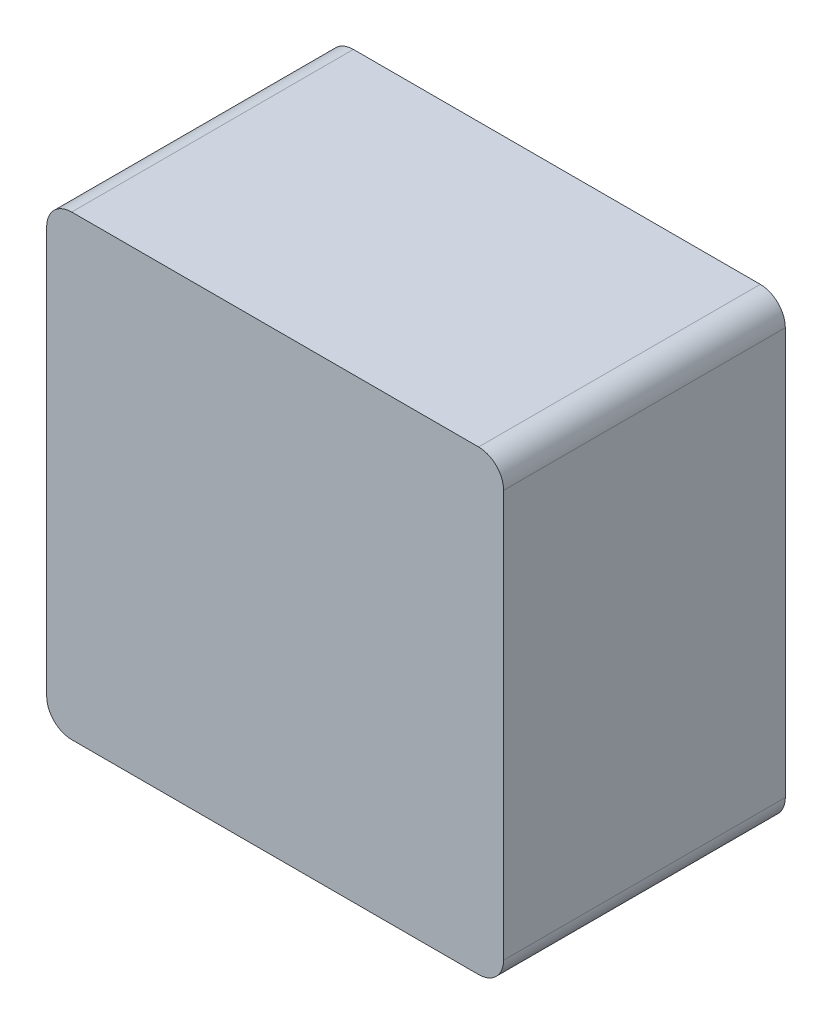
from build123d import *

# Parameters (mm, degrees)
ESQUISSE1_W             = 7.3
ESQUISSE1_H             = 7.3
BOSS_EXTRU_1_DEPTH      = 4.5
CONG_1_R                = 0.4
ESQUISSE2_R             = 3.194001284
ENL_V_MAT_EXTRU_1_DEPTH = 0.5
ESQUISSE4_R             = 2.722665782
BOSS_EXTRU_2_DEPTH      = 0.5
CONG_2_R                = 0.1
CONG_3_R                = 0.1
ESQUISSE5_W             = 0.110070801
ESQUISSE5_H             = 0.110070801
ENL_V_MAT_EXTRU_2_DEPTH = 0.15


with BuildPart() as part:
    # Esquisse1 → Boss.-Extru.1 (new body)
    with BuildSketch(Plane.XY):
        Rectangle(ESQUISSE1_W, ESQUISSE1_H)
    extrude(amount=BOSS_EXTRU_1_DEPTH)

    # Congé1
    cong_1_edges = [part.edges().sort_by_distance(p)[0] for p in [
        (3.65, -3.65, 2.25),
        (-3.65, -3.65, 2.25),
        (-3.65, 3.65, 2.25),
        (3.65, 3.65, 2.25),
    ]]
    fillet(cong_1_edges, radius=CONG_1_R)

    # Esquisse2 → Enlèv. mat.-Extru.1 (cut)
    with BuildSketch(Plane(origin=(0, 0, 0), x_dir=(-1, 0, 0), z_dir=(0, 0, -1))):
        Circle(ESQUISSE2_R)
    extrude(amount=-ENL_V_MAT_EXTRU_1_DEPTH, mode=Mode.SUBTRACT)

    # Esquisse4 → Boss.-Extru.2 (add)
    with BuildSketch(Plane(origin=(0, 0, 0.5), x_dir=(-1, 0, 0), z_dir=(0, 0, -1))):
        Circle(ESQUISSE4_R)
    extrude(amount=BOSS_EXTRU_2_DEPTH)

    # Congé2
    cong_2_edges = [part.edges().sort_by_distance(p)[0] for p in [
        (2.722665782, 0, 0),
    ]]
    fillet(cong_2_edges, radius=CONG_2_R)

    # Congé3
    cong_3_edges = [part.edges().sort_by_distance(p)[0] for p in [
        (3.194001284, 0, 0),
    ]]
    fillet(cong_3_edges, radius=CONG_3_R)

    # Esquisse5 → Enlèv. mat.-Extru.2 (cut)
    with BuildSketch(Plane(origin=(0, 0, 0), x_dir=(-1, 0, 0), z_dir=(0, 0, -1))):
        with BuildLine():
            add(Edge.make_bspline(
                [(-0.934817078, 0.083251061), (-0.928955448, 0.081995484), (-0.917467244, 0.07953468), (-0.900940309, 0.074214743), (-0.88562815, 0.0674044), (-0.871243346, 0.059681976), (-0.858158053, 0.050281794), (-0.846155594, 0.039704894), (-0.83522412, 0.027794835), (-0.825475205, 0.014775308), (-0.817032773, 0.000884688), (-0.809399465, -0.013262172), (-0.803016569, -0.027741979), (-0.797817027, -0.042594032), (-0.793736289, -0.057688985), (-0.790942899, -0.073174388), (-0.789178597, -0.088902263), (-0.788916836, -0.099518177), (-0.788785646, -0.104838674)],
                knots=[0, 0, 0, 0, 1.7977e-05, 3.5233e-05, 5.1965e-05, 6.82e-05, 8.4121e-05, 0.000100183, 0.000116117, 0.000132534, 0.000148891, 0.000164839, 0.00018073, 0.000196306, 0.000212008, 0.000227586, 0.000243471, 0.000259431, 0.000259431, 0.000259431, 0.000259431], degree=3))
            add(Edge.make_bspline(
                [(-0.788785646, -0.104838674), (-0.789046711, -0.113344299), (-0.789559799, -0.130060944), (-0.792984015, -0.154560432), (-0.798944283, -0.17783618), (-0.807350159, -0.199929267), (-0.817933009, -0.221001066), (-0.831218583, -0.240711955), (-0.846660871, -0.259371296), (-0.864378941, -0.276485435), (-0.883666398, -0.29203868), (-0.904068164, -0.305702124), (-0.925379623, -0.317368932), (-0.947727579, -0.326736661), (-0.970938921, -0.334173202), (-0.995149022, -0.339250482), (-1.020253593, -0.342482377), (-1.037320898, -0.342903319), (-1.045982333, -0.343116941)],
                knots=[0, 0, 0, 0, 2.5516e-05, 5.0148e-05, 7.4038e-05, 9.7443e-05, 0.000120938, 0.000144614, 0.000168597, 0.000193474, 0.000218381, 0.000242838, 0.000267045, 0.000291148, 0.000315426, 0.000340051, 0.000365262, 0.000391239, 0.000391239, 0.000391239, 0.000391239], degree=3))
            add(Edge.make_bspline(
                [(-1.045982333, -0.343116941), (-1.05422647, -0.342950254), (-1.070399565, -0.342623251), (-1.09406705, -0.339657235), (-1.116686533, -0.335315361), (-1.138069305, -0.328553388), (-1.158537675, -0.32037952), (-1.177756847, -0.309981996), (-1.19590383, -0.297817127), (-1.212887842, -0.284017603), (-1.22832784, -0.268463629), (-1.242300717, -0.251792798), (-1.254437288, -0.233732346), (-1.264890302, -0.214590233), (-1.273553823, -0.194142376), (-1.280544902, -0.17259103), (-1.285961492, -0.149795802), (-1.288045572, -0.134099866), (-1.289107468, -0.126102351)],
                knots=[0, 0, 0, 0, 2.4721e-05, 4.8497e-05, 7.1464e-05, 9.3718e-05, 0.000115668, 0.000137493, 0.000159132, 0.000181133, 0.000203023, 0.000224784, 0.000246293, 0.000268192, 0.000290118, 0.000312812, 0.000336098, 0.000360288, 0.000360288, 0.000360288, 0.000360288], degree=3))
            Line((-1.289107468, -0.126102351), (-1.189043104, -0.112968903))
            add(Edge.make_bspline(
                [(-1.189043104, -0.112968903), (-1.187869842, -0.119084022), (-1.185588589, -0.13097407), (-1.180981695, -0.148015924), (-1.175868995, -0.163923344), (-1.169917951, -0.178660921), (-1.163271775, -0.192224935), (-1.155835105, -0.204528163), (-1.147857078, -0.215724232), (-1.139121523, -0.225797432), (-1.129489933, -0.234545988), (-1.119314216, -0.242322367), (-1.108285068, -0.248772031), (-1.096492784, -0.253891553), (-1.084040381, -0.25799322), (-1.070856449, -0.260982315), (-1.056918951, -0.262676847), (-1.047393948, -0.262934315), (-1.04254262, -0.26306545)],
                knots=[0, 0, 0, 0, 1.8674e-05, 3.6309e-05, 5.2922e-05, 6.8774e-05, 8.3948e-05, 9.8186e-05, 0.000111854, 0.00012515, 0.000138097, 0.000150824, 0.000163508, 0.000176319, 0.000189322, 0.000202787, 0.000216809, 0.000231363, 0.000231363, 0.000231363, 0.000231363], degree=3))
            add(Edge.make_bspline(
                [(-1.04254262, -0.26306545), (-1.037274024, -0.262889623), (-1.026906493, -0.262543632), (-1.011630134, -0.26057244), (-0.997071807, -0.256857145), (-0.982993851, -0.252115273), (-0.969709522, -0.245512409), (-0.956762053, -0.237980552), (-0.944770896, -0.228585182), (-0.933363946, -0.218186466), (-0.922992346, -0.206725321), (-0.913846492, -0.194492646), (-0.906184461, -0.181561033), (-0.899673279, -0.168126036), (-0.894805924, -0.153885853), (-0.891481265, -0.139039413), (-0.889103485, -0.123624307), (-0.888935361, -0.113134612), (-0.888850011, -0.107809334)],
                knots=[0, 0, 0, 0, 1.5811e-05, 3.1112e-05, 4.6091e-05, 6.0826e-05, 7.5581e-05, 9.0517e-05, 0.000105683, 0.000121176, 0.000136783, 0.000151981, 0.000166916, 0.000181812, 0.000196695, 0.000211941, 0.000227419, 0.000243379, 0.000243379, 0.000243379, 0.000243379], degree=3))
            add(Edge.make_bspline(
                [(-0.888850011, -0.107809334), (-0.888946861, -0.102693533), (-0.889136437, -0.092679816), (-0.891317824, -0.077987904), (-0.894482425, -0.063912347), (-0.899224884, -0.050563446), (-0.905274275, -0.037933065), (-0.912399194, -0.025835944), (-0.921125, -0.014510395), (-0.931080317, -0.003993525), (-0.941970542, 0.005691078), (-0.953735707, 0.01426011), (-0.966468529, 0.021210001), (-0.979886946, 0.027113089), (-0.994157574, 0.031592992), (-1.009215166, 0.034913458), (-1.02508845, 0.036776014), (-1.035919086, 0.037008803), (-1.041448166, 0.037127643)],
                knots=[0, 0, 0, 0, 1.5335e-05, 3.0017e-05, 4.4467e-05, 5.856e-05, 7.2407e-05, 8.6431e-05, 0.000100597, 0.000115197, 0.000129817, 0.000144267, 0.000158754, 0.000173249, 0.000188182, 0.000203546, 0.000219449, 0.000236034, 0.000236034, 0.000236034, 0.000236034], degree=3))
            add(Edge.make_bspline(
                [(-1.041448166, 0.037127643), (-1.0463002, 0.036993927), (-1.056557343, 0.036711252), (-1.072686406, 0.034677129), (-1.090380444, 0.031563915), (-1.102595372, 0.028648066), (-1.108991612, 0.027121207)],
                knots=[0, 0, 0, 0, 1.4554e-05, 3.0767e-05, 4.8709e-05, 6.8432e-05, 6.8432e-05, 6.8432e-05, 6.8432e-05], degree=3))
            Line((-1.108991612, 0.027121207), (-1.098203423, 0.117179135))
            add(Edge.make_bspline(
                [(-1.098203423, 0.117179135), (-1.092312242, 0.117164913), (-1.081201319, 0.11713809), (-1.065521915, 0.118101061), (-1.05178104, 0.118836006), (-1.039480723, 0.120420584), (-1.027885395, 0.123043577), (-1.01598431, 0.126660274), (-1.00355172, 0.131763898), (-0.990564054, 0.137816035), (-0.977840072, 0.145370559), (-0.965972053, 0.154452217), (-0.955506667, 0.165256417), (-0.945994239, 0.177239976), (-0.938227971, 0.190941451), (-0.93280921, 0.206285776), (-0.929424798, 0.223141824), (-0.929063659, 0.234894031), (-0.928875756, 0.241008786)],
                knots=[0, 0, 0, 0, 1.7668e-05, 3.3323e-05, 4.7114e-05, 5.8944e-05, 7.0476e-05, 8.2741e-05, 9.6212e-05, 0.000110759, 0.000125694, 0.000140518, 0.000155444, 0.000170706, 0.000186318, 0.000202441, 0.000219336, 0.000237662, 0.000237662, 0.000237662, 0.000237662], degree=3))
            add(Edge.make_bspline(
                [(-0.928875756, 0.241008786), (-0.929019925, 0.245493993), (-0.929300765, 0.254231115), (-0.930785244, 0.266984476), (-0.933659279, 0.27890948), (-0.937494786, 0.290145522), (-0.942815255, 0.300462985), (-0.948791567, 0.310286297), (-0.956283988, 0.319068045), (-0.967462375, 0.329538807), (-0.98293999, 0.340642356), (-1.003343288, 0.350229793), (-1.025199467, 0.3563731), (-1.040312605, 0.35700935), (-1.04801489, 0.357333609)],
                knots=[0, 0, 0, 0, 1.3461e-05, 2.6221e-05, 3.8433e-05, 5.0202e-05, 6.1739e-05, 7.3191e-05, 8.4621e-05, 9.6235e-05, 0.000119099, 0.00014141, 0.000163597, 0.000186657, 0.000186657, 0.000186657, 0.000186657], degree=3))
            add(Edge.make_bspline(
                [(-1.04801489, 0.357333609), (-1.052397874, 0.357203509), (-1.061041273, 0.356946946), (-1.073666638, 0.355224675), (-1.085693087, 0.352357214), (-1.097140097, 0.348554815), (-1.10785611, 0.343232962), (-1.118037726, 0.337057284), (-1.127538682, 0.329553), (-1.136368607, 0.321000061), (-1.144553754, 0.311465748), (-1.151768385, 0.300810393), (-1.158334019, 0.289269321), (-1.164095261, 0.276702932), (-1.16915415, 0.263245739), (-1.173095818, 0.248761848), (-1.176649907, 0.233396641), (-1.17822602, 0.222729804), (-1.179036667, 0.217243499)],
                knots=[0, 0, 0, 0, 1.3148e-05, 2.5929e-05, 3.814e-05, 5.0205e-05, 6.2022e-05, 7.3955e-05, 8.5872e-05, 9.8256e-05, 0.000110789, 0.000123495, 0.000136799, 0.00015058, 0.000164927, 0.000179874, 0.000195578, 0.000212209, 0.000212209, 0.000212209, 0.000212209], degree=3))
            Line((-1.179036667, 0.217243499), (-1.279101032, 0.234754763))
            add(Edge.make_bspline(
                [(-1.279101032, 0.234754763), (-1.277521177, 0.242970972), (-1.274423611, 0.259080203), (-1.267526712, 0.282086764), (-1.259919776, 0.303723278), (-1.250322493, 0.323470115), (-1.23986717, 0.341936114), (-1.227494505, 0.358446094), (-1.214206293, 0.373728431), (-1.199269996, 0.387080119), (-1.183400195, 0.398944077), (-1.166644347, 0.409129219), (-1.149278906, 0.418059079), (-1.130943126, 0.424894064), (-1.112049107, 0.430748185), (-1.092278802, 0.434521784), (-1.071789356, 0.436954061), (-1.057872164, 0.437240264), (-1.0508292, 0.437385101)],
                knots=[0, 0, 0, 0, 2.5083e-05, 4.918e-05, 7.1982e-05, 9.3802e-05, 0.00011496, 0.000135537, 0.000155584, 0.00017562, 0.000195508, 0.000214949, 0.000234387, 0.000253987, 0.000273575, 0.000293659, 0.000314275, 0.000335397, 0.000335397, 0.000335397, 0.000335397], degree=3))
            add(Edge.make_bspline(
                [(-1.0508292, 0.437385101), (-1.043056697, 0.437197815), (-1.02782999, 0.436830912), (-1.005475808, 0.434158042), (-0.984149856, 0.429580178), (-0.963730662, 0.423408837), (-0.944411166, 0.415157543), (-0.925974867, 0.405312573), (-0.908613571, 0.393475804), (-0.892241574, 0.380179054), (-0.877585895, 0.365366656), (-0.864397033, 0.349881162), (-0.853419296, 0.333383232), (-0.844475033, 0.316055058), (-0.837318993, 0.297959556), (-0.832391109, 0.279005142), (-0.829282405, 0.259248531), (-0.828970295, 0.245815396), (-0.828811392, 0.238976228)],
                knots=[0, 0, 0, 0, 2.3315e-05, 4.5675e-05, 6.7417e-05, 8.8683e-05, 0.000109562, 0.000130339, 0.000151284, 0.000172504, 0.00019351, 0.000213709, 0.000233439, 0.00025281, 0.000272118, 0.000291687, 0.000311455, 0.000331958, 0.000331958, 0.000331958, 0.000331958], degree=3))
            add(Edge.make_bspline(
                [(-0.828811392, 0.238976228), (-0.829152235, 0.230355601), (-0.82981484, 0.213596936), (-0.8346485, 0.189389228), (-0.84309756, 0.16716038), (-0.854745851, 0.146692692), (-0.870018075, 0.128309286), (-0.888415414, 0.11169854), (-0.910187993, 0.097058496), (-0.926418634, 0.089298816), (-0.934817078, 0.085283619)],
                knots=[0, 0, 0, 0, 2.5855e-05, 5.0263e-05, 7.3668e-05, 9.692e-05, 0.000120583, 0.000145046, 0.000171065, 0.000198964, 0.000198964, 0.000198964, 0.000198964], degree=3))
            Line((-0.934817078, 0.085283619), (-0.934817078, 0.083251061))
        make_face()
        with Locations((-0.5836537, -0.278075105)):
            Rectangle(ESQUISSE5_W, ESQUISSE5_H)
        with BuildLine():
            add(Edge.make_bspline(
                [(-0.034237799, 0.083251061), (-0.028376169, 0.081995484), (-0.016887965, 0.07953468), (-0.000361029, 0.074214743), (0.014951129, 0.0674044), (0.029335933, 0.059681976), (0.042421226, 0.050281794), (0.054423685, 0.039704894), (0.065355159, 0.027794835), (0.075104074, 0.014775308), (0.083546506, 0.000884688), (0.091179814, -0.013262172), (0.09756271, -0.027741979), (0.102762252, -0.042594032), (0.10684299, -0.057688985), (0.10963638, -0.073174388), (0.111400682, -0.088902263), (0.111662443, -0.099518177), (0.111793633, -0.104838674)],
                knots=[0, 0, 0, 0, 1.7977e-05, 3.5233e-05, 5.1965e-05, 6.82e-05, 8.4121e-05, 0.000100183, 0.000116117, 0.000132534, 0.000148891, 0.000164839, 0.00018073, 0.000196306, 0.000212008, 0.000227586, 0.000243471, 0.000259431, 0.000259431, 0.000259431, 0.000259431], degree=3))
            add(Edge.make_bspline(
                [(0.111793633, -0.104838674), (0.111532568, -0.113344299), (0.11101948, -0.130060944), (0.107595264, -0.154560432), (0.101634996, -0.17783618), (0.09322912, -0.199929267), (0.08264627, -0.221001066), (0.069360697, -0.240711955), (0.053918408, -0.259371296), (0.036200338, -0.276485435), (0.016912882, -0.29203868), (-0.003488885, -0.305702124), (-0.024800344, -0.317368932), (-0.0471483, -0.326736661), (-0.070359642, -0.334173202), (-0.094569743, -0.339250482), (-0.119674314, -0.342482377), (-0.136741619, -0.342903319), (-0.145403054, -0.343116941)],
                knots=[0, 0, 0, 0, 2.5516e-05, 5.0148e-05, 7.4038e-05, 9.7443e-05, 0.000120938, 0.000144614, 0.000168597, 0.000193474, 0.000218381, 0.000242838, 0.000267045, 0.000291148, 0.000315426, 0.000340051, 0.000365262, 0.000391239, 0.000391239, 0.000391239, 0.000391239], degree=3))
            add(Edge.make_bspline(
                [(-0.145403054, -0.343116941), (-0.153647191, -0.342950254), (-0.169820286, -0.342623251), (-0.193487771, -0.339657235), (-0.216107254, -0.335315361), (-0.237490026, -0.328553388), (-0.257958396, -0.32037952), (-0.277177568, -0.309981996), (-0.295324551, -0.297817127), (-0.312308563, -0.284017603), (-0.32774856, -0.268463629), (-0.341721437, -0.251792798), (-0.353858009, -0.233732346), (-0.364311023, -0.214590233), (-0.372974544, -0.194142376), (-0.379965623, -0.17259103), (-0.385382213, -0.149795802), (-0.387466293, -0.134099866), (-0.388528189, -0.126102351)],
                knots=[0, 0, 0, 0, 2.4721e-05, 4.8497e-05, 7.1464e-05, 9.3718e-05, 0.000115668, 0.000137493, 0.000159132, 0.000181133, 0.000203023, 0.000224784, 0.000246293, 0.000268192, 0.000290118, 0.000312812, 0.000336098, 0.000360288, 0.000360288, 0.000360288, 0.000360288], degree=3))
            Line((-0.388528189, -0.126102351), (-0.288463825, -0.112968903))
            add(Edge.make_bspline(
                [(-0.288463825, -0.112968903), (-0.287290563, -0.119084022), (-0.285009309, -0.13097407), (-0.280402416, -0.148015924), (-0.275289716, -0.163923344), (-0.269338672, -0.178660921), (-0.262692496, -0.192224935), (-0.255255826, -0.204528163), (-0.247277799, -0.215724232), (-0.238542244, -0.225797432), (-0.228910654, -0.234545988), (-0.218734937, -0.242322367), (-0.207705789, -0.248772031), (-0.195913505, -0.253891553), (-0.183461102, -0.25799322), (-0.17027717, -0.260982315), (-0.156339672, -0.262676847), (-0.146814669, -0.262934315), (-0.141963341, -0.26306545)],
                knots=[0, 0, 0, 0, 1.8674e-05, 3.6309e-05, 5.2922e-05, 6.8774e-05, 8.3948e-05, 9.8186e-05, 0.000111854, 0.00012515, 0.000138097, 0.000150824, 0.000163508, 0.000176319, 0.000189322, 0.000202787, 0.000216809, 0.000231363, 0.000231363, 0.000231363, 0.000231363], degree=3))
            add(Edge.make_bspline(
                [(-0.141963341, -0.26306545), (-0.136694745, -0.262889623), (-0.126327214, -0.262543632), (-0.111050855, -0.26057244), (-0.096492528, -0.256857145), (-0.082414572, -0.252115273), (-0.069130243, -0.245512409), (-0.056182774, -0.237980552), (-0.044191617, -0.228585182), (-0.032784666, -0.218186466), (-0.022413067, -0.206725321), (-0.013267213, -0.194492646), (-0.005605182, -0.181561033), (0.000906, -0.168126036), (0.005773355, -0.153885853), (0.009098014, -0.139039413), (0.011475795, -0.123624307), (0.011643918, -0.113134612), (0.011729269, -0.107809334)],
                knots=[0, 0, 0, 0, 1.5811e-05, 3.1112e-05, 4.6091e-05, 6.0826e-05, 7.5581e-05, 9.0517e-05, 0.000105683, 0.000121176, 0.000136783, 0.000151981, 0.000166916, 0.000181812, 0.000196695, 0.000211941, 0.000227419, 0.000243379, 0.000243379, 0.000243379, 0.000243379], degree=3))
            add(Edge.make_bspline(
                [(0.011729269, -0.107809334), (0.011632418, -0.102693533), (0.011442842, -0.092679816), (0.009261455, -0.077987904), (0.006096854, -0.063912347), (0.001354395, -0.050563446), (-0.004694996, -0.037933065), (-0.011819915, -0.025835944), (-0.020545721, -0.014510395), (-0.030501038, -0.003993525), (-0.041391263, 0.005691078), (-0.053156427, 0.01426011), (-0.06588925, 0.021210001), (-0.079307667, 0.027113089), (-0.093578295, 0.031592992), (-0.108635887, 0.034913458), (-0.124509171, 0.036776014), (-0.135339807, 0.037008803), (-0.140868887, 0.037127643)],
                knots=[0, 0, 0, 0, 1.5335e-05, 3.0017e-05, 4.4467e-05, 5.856e-05, 7.2407e-05, 8.6431e-05, 0.000100597, 0.000115197, 0.000129817, 0.000144267, 0.000158754, 0.000173249, 0.000188182, 0.000203546, 0.000219449, 0.000236034, 0.000236034, 0.000236034, 0.000236034], degree=3))
            add(Edge.make_bspline(
                [(-0.140868887, 0.037127643), (-0.145720921, 0.036993927), (-0.155978064, 0.036711252), (-0.172107127, 0.034677129), (-0.189801165, 0.031563915), (-0.202016093, 0.028648066), (-0.208412333, 0.027121207)],
                knots=[0, 0, 0, 0, 1.4554e-05, 3.0767e-05, 4.8709e-05, 6.8432e-05, 6.8432e-05, 6.8432e-05, 6.8432e-05], degree=3))
            Line((-0.208412333, 0.027121207), (-0.197624144, 0.117179135))
            add(Edge.make_bspline(
                [(-0.197624144, 0.117179135), (-0.191732963, 0.117164913), (-0.180622039, 0.11713809), (-0.164942636, 0.118101061), (-0.151201761, 0.118836006), (-0.138901444, 0.120420584), (-0.127306116, 0.123043577), (-0.115405031, 0.126660274), (-0.102972441, 0.131763898), (-0.089984775, 0.137816035), (-0.077260793, 0.145370559), (-0.065392774, 0.154452217), (-0.054927388, 0.165256417), (-0.04541496, 0.177239976), (-0.037648692, 0.190941451), (-0.032229931, 0.206285776), (-0.028845519, 0.223141824), (-0.02848438, 0.234894031), (-0.028296477, 0.241008786)],
                knots=[0, 0, 0, 0, 1.7668e-05, 3.3323e-05, 4.7114e-05, 5.8944e-05, 7.0476e-05, 8.2741e-05, 9.6212e-05, 0.000110759, 0.000125694, 0.000140518, 0.000155444, 0.000170706, 0.000186318, 0.000202441, 0.000219336, 0.000237662, 0.000237662, 0.000237662, 0.000237662], degree=3))
            add(Edge.make_bspline(
                [(-0.028296477, 0.241008786), (-0.028440646, 0.245493993), (-0.028721486, 0.254231115), (-0.030205965, 0.266984476), (-0.03308, 0.27890948), (-0.036915507, 0.290145522), (-0.042235976, 0.300462985), (-0.048212288, 0.310286297), (-0.055704709, 0.319068045), (-0.066883096, 0.329538807), (-0.082360711, 0.340642356), (-0.102764009, 0.350229793), (-0.124620187, 0.3563731), (-0.139733326, 0.35700935), (-0.147435611, 0.357333609)],
                knots=[0, 0, 0, 0, 1.3461e-05, 2.6221e-05, 3.8433e-05, 5.0202e-05, 6.1739e-05, 7.3191e-05, 8.4621e-05, 9.6235e-05, 0.000119099, 0.00014141, 0.000163597, 0.000186657, 0.000186657, 0.000186657, 0.000186657], degree=3))
            add(Edge.make_bspline(
                [(-0.147435611, 0.357333609), (-0.151818595, 0.357203509), (-0.160461994, 0.356946946), (-0.173087359, 0.355224675), (-0.185113808, 0.352357214), (-0.196560818, 0.348554815), (-0.207276831, 0.343232962), (-0.217458446, 0.337057284), (-0.226959403, 0.329553), (-0.235789328, 0.321000061), (-0.243974475, 0.311465748), (-0.251189106, 0.300810393), (-0.25775474, 0.289269321), (-0.263515982, 0.276702932), (-0.268574871, 0.263245739), (-0.272516539, 0.248761848), (-0.276070628, 0.233396641), (-0.277646741, 0.222729804), (-0.278457388, 0.217243499)],
                knots=[0, 0, 0, 0, 1.3148e-05, 2.5929e-05, 3.814e-05, 5.0205e-05, 6.2022e-05, 7.3955e-05, 8.5872e-05, 9.8256e-05, 0.000110789, 0.000123495, 0.000136799, 0.00015058, 0.000164927, 0.000179874, 0.000195578, 0.000212209, 0.000212209, 0.000212209, 0.000212209], degree=3))
            Line((-0.278457388, 0.217243499), (-0.378521752, 0.234754763))
            add(Edge.make_bspline(
                [(-0.378521752, 0.234754763), (-0.376941898, 0.242970972), (-0.373844332, 0.259080203), (-0.366947433, 0.282086764), (-0.359340497, 0.303723278), (-0.349743213, 0.323470115), (-0.339287891, 0.341936114), (-0.326915226, 0.358446094), (-0.313627014, 0.373728431), (-0.298690717, 0.387080119), (-0.282820916, 0.398944077), (-0.266065068, 0.409129219), (-0.248699627, 0.418059079), (-0.230363847, 0.424894064), (-0.211469828, 0.430748185), (-0.191699523, 0.434521784), (-0.171210076, 0.436954061), (-0.157292885, 0.437240264), (-0.150249921, 0.437385101)],
                knots=[0, 0, 0, 0, 2.5083e-05, 4.918e-05, 7.1982e-05, 9.3802e-05, 0.00011496, 0.000135537, 0.000155584, 0.00017562, 0.000195508, 0.000214949, 0.000234387, 0.000253987, 0.000273575, 0.000293659, 0.000314275, 0.000335397, 0.000335397, 0.000335397, 0.000335397], degree=3))
            add(Edge.make_bspline(
                [(-0.150249921, 0.437385101), (-0.142477418, 0.437197815), (-0.127250711, 0.436830912), (-0.104896529, 0.434158042), (-0.083570576, 0.429580178), (-0.063151383, 0.423408837), (-0.043831886, 0.415157543), (-0.025395587, 0.405312573), (-0.008034292, 0.393475804), (0.008337705, 0.380179054), (0.022993384, 0.365366656), (0.036182246, 0.349881162), (0.047159984, 0.333383232), (0.056104246, 0.316055058), (0.063260286, 0.297959556), (0.06818817, 0.279005142), (0.071296874, 0.259248531), (0.071608984, 0.245815396), (0.071767887, 0.238976228)],
                knots=[0, 0, 0, 0, 2.3315e-05, 4.5675e-05, 6.7417e-05, 8.8683e-05, 0.000109562, 0.000130339, 0.000151284, 0.000172504, 0.00019351, 0.000213709, 0.000233439, 0.00025281, 0.000272118, 0.000291687, 0.000311455, 0.000331958, 0.000331958, 0.000331958, 0.000331958], degree=3))
            add(Edge.make_bspline(
                [(0.071767887, 0.238976228), (0.071427044, 0.230355601), (0.070764439, 0.213596936), (0.065930779, 0.189389228), (0.057481719, 0.16716038), (0.045833428, 0.146692692), (0.030561204, 0.128309286), (0.012163865, 0.11169854), (-0.009608713, 0.097058496), (-0.025839355, 0.089298816), (-0.034237799, 0.085283619)],
                knots=[0, 0, 0, 0, 2.5855e-05, 5.0263e-05, 7.3668e-05, 9.692e-05, 0.000120583, 0.000145046, 0.000171065, 0.000198964, 0.000198964, 0.000198964, 0.000198964], degree=3))
            Line((-0.034237799, 0.085283619), (-0.034237799, 0.083251061))
        make_face()
        with BuildLine():
            Line((0.692166946, -0.333110505), (0.602109018, -0.333110505))
            Line((0.602109018, -0.333110505), (0.602109018, -0.248055795))
            Line((0.602109018, -0.248055795), (0.599451058, -0.248055795))
            add(Edge.make_bspline(
                [(0.599451058, -0.248055795), (0.593980453, -0.255582131), (0.583282086, -0.270300704), (0.564911998, -0.289793428), (0.544981582, -0.306240043), (0.523638481, -0.319893674), (0.500591623, -0.330130204), (0.476292738, -0.337815601), (0.450396673, -0.342181315), (0.432640834, -0.342800273), (0.423556668, -0.343116941)],
                knots=[0, 0, 0, 0, 2.7894e-05, 5.4549e-05, 8.0093e-05, 0.000105251, 0.000130303, 0.000155523, 0.000181536, 0.000208785, 0.000208785, 0.000208785, 0.000208785], degree=3))
            add(Edge.make_bspline(
                [(0.423556668, -0.343116941), (0.413945439, -0.342782178), (0.394955487, -0.342120751), (0.367044058, -0.336973809), (0.340240009, -0.328498716), (0.319107024, -0.318594543), (0.303148521, -0.309281259), (0.292282726, -0.301452181), (0.28225793, -0.293129538), (0.273425811, -0.284064322), (0.265437702, -0.274479211), (0.258771207, -0.264065183), (0.252905935, -0.2531273), (0.246572346, -0.237195724), (0.240609225, -0.215094304), (0.235557969, -0.185941394), (0.232451842, -0.153269084), (0.232070917, -0.130331036), (0.23187087, -0.118284823)],
                knots=[0, 0, 0, 0, 2.882e-05, 5.6943e-05, 8.4831e-05, 0.00011295, 0.000126759, 0.000140209, 0.000153081, 0.000165796, 0.000178128, 0.000190444, 0.000202823, 0.000215308, 0.000241788, 0.000271324, 0.000303995, 0.000340128, 0.000340128, 0.000340128, 0.000340128], degree=3))
            Line((0.23187087, -0.118284823), (0.23187087, 0.227249936))
            Line((0.23187087, 0.227249936), (0.331935234, 0.227249936))
            Line((0.331935234, 0.227249936), (0.331935234, -0.082793243))
            add(Edge.make_bspline(
                [(0.331935234, -0.082793243), (0.331973159, -0.088786896), (0.332046045, -0.100305907), (0.332377244, -0.116879244), (0.332776304, -0.132156694), (0.333609101, -0.146121334), (0.334459774, -0.15880086), (0.3357441, -0.17010924), (0.337158453, -0.180115972), (0.339033051, -0.191683406), (0.343393565, -0.20473574), (0.351040531, -0.219122679), (0.362023421, -0.231701612), (0.375280417, -0.242798338), (0.390732436, -0.251790165), (0.407852939, -0.258451761), (0.42645066, -0.262418527), (0.439328779, -0.262846553), (0.445914799, -0.26306545)],
                knots=[0, 0, 0, 0, 1.7981e-05, 3.4557e-05, 4.973e-05, 6.3824e-05, 7.6523e-05, 8.7849e-05, 9.7954e-05, 0.000106848, 0.000122967, 0.000138989, 0.000155405, 0.000172721, 0.00019066, 0.000208778, 0.000227637, 0.000247377, 0.000247377, 0.000247377, 0.000247377], degree=3))
            add(Edge.make_bspline(
                [(0.445914799, -0.26306545), (0.454663981, -0.262609155), (0.472122263, -0.261698657), (0.497808766, -0.254411442), (0.522531971, -0.242634255), (0.542201576, -0.229294292), (0.556943069, -0.215627107), (0.56639095, -0.202264557), (0.574432401, -0.186507899), (0.580853181, -0.168287992), (0.586033209, -0.147674587), (0.589483318, -0.124530142), (0.591669855, -0.098939493), (0.591954346, -0.081026203), (0.592102582, -0.071692353)],
                knots=[0, 0, 0, 0, 2.6216e-05, 5.2311e-05, 7.9448e-05, 0.000108115, 0.000123265, 0.000139496, 0.000156908, 0.000176197, 0.000197319, 0.000220582, 0.000246317, 0.000274314, 0.000274314, 0.000274314, 0.000274314], degree=3))
            Line((0.592102582, -0.071692353), (0.592102582, 0.227249936))
            Line((0.592102582, 0.227249936), (0.692166946, 0.227249936))
            Line((0.692166946, 0.227249936), (0.692166946, -0.333110505))
        make_face()
        Polygon((1.452656115, -0.333110505), (1.352591751, -0.333110505), (1.352591751, 0.027121207), (0.952334293, 0.027121207), (0.952334293, -0.333110505), (0.852269929, -0.333110505), (0.852269929, 0.437385101), (0.952334293, 0.437385101), (0.952334293, 0.117179135), (1.352591751, 0.117179135), (1.352591751, 0.437385101), (1.452656115, 0.437385101), align=None)
    extrude(amount=-ENL_V_MAT_EXTRU_2_DEPTH, mode=Mode.SUBTRACT)


solid = part.part
